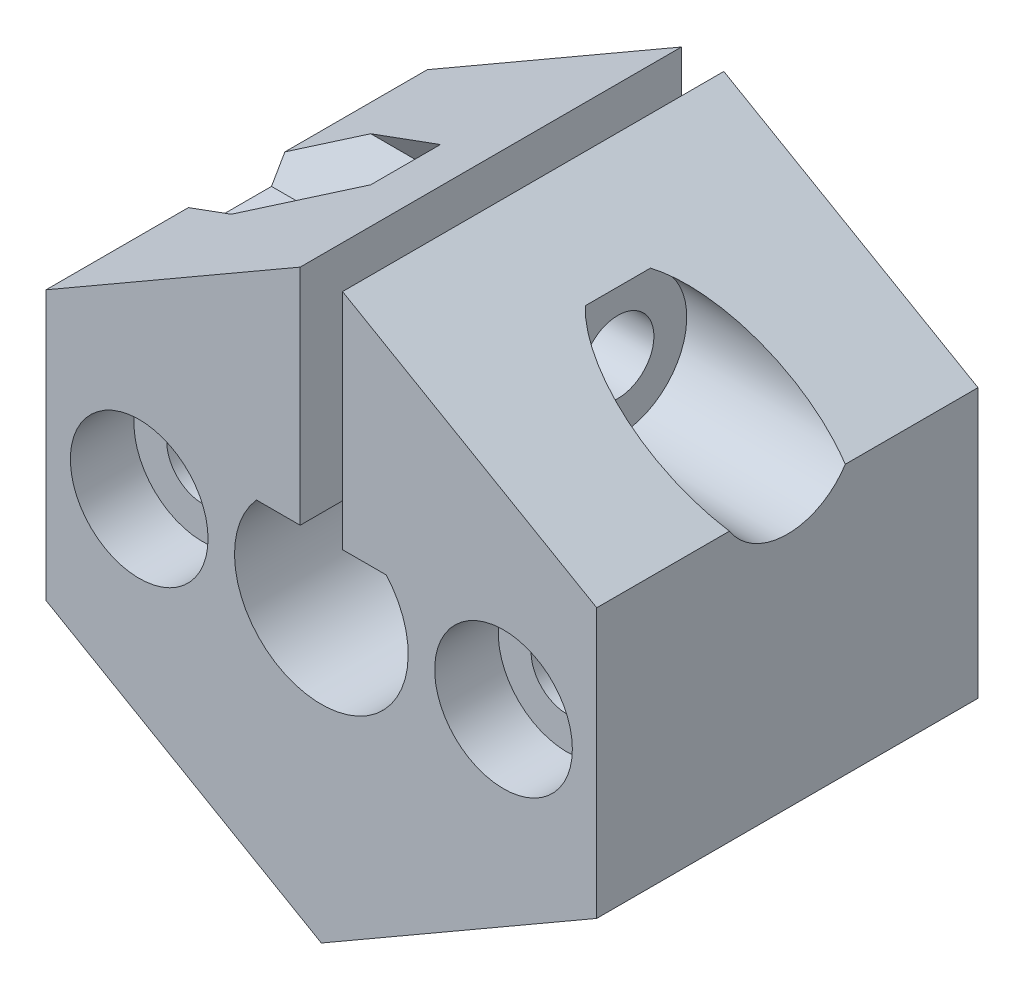
from build123d import *

# Parameters (mm, degrees)
BOSS_EXTRUDE1_DEPTH            = 18
SKETCH41_R                     = 1.7
CUT_EXTRUDE7_DEPTH             = 18
CBORE_FOR_M3_SHCS1_D           = 3.4
CBORE_FOR_M3_SHCS1_CBORE_D     = 6.5
CBORE_FOR_M3_SHCS1_CBORE_DEPTH = 3
CBORE_FOR_M3_SHCS2_D           = 3.4
CBORE_FOR_M3_SHCS2_CBORE_D     = 6.5
CBORE_FOR_M3_SHCS2_CBORE_DEPTH = 3
SKETCH52_R                     = 1.7
CUT_EXTRUDE10_DEPTH            = 15
CUT_EXTRUDE10_DEPTH_BACK       = 15
SKETCH58_R                     = 3.25
CUT_EXTRUDE11_DEPTH            = 8
CUT_EXTRUDE12_DEPTH            = 4
CUT_EXTRUDE12_DEPTH_BACK       = 6


with BuildPart() as part:
    # Sketch1 → Boss-Extrude1 (new body)
    with BuildSketch(Plane(origin=(0, 0, 0), x_dir=(0, 1, 0), z_dir=(0, 0, 1))):
        with BuildLine():
            Line((-6.350852961, -13), (6.350852961, -13))
            Line((6.350852961, -13), (13.279056191, -1))
            Line((13.279056191, -1), (2.724986242, -1))
            Line((2.724986242, -1), (2.724986242, -3.063404965))
            ThreePointArc((2.724986242, -3.063404965), (-1.678921738, -3.740484166), (-4.1, 0))
            ThreePointArc((-4.1, 0), (-1.678921738, 3.740484166), (2.724986242, 3.063404965))
            Line((2.724986242, 3.063404965), (2.724986242, 1))
            Line((2.724986242, 1), (13.279056191, 1))
            Line((13.279056191, 1), (6.350852961, 13))
            Line((6.350852961, 13), (-6.350852961, 13))
            Line((-6.350852961, 13), (-13.856406461, 0))
            Line((-13.856406461, 0), (-6.350852961, -13))
        make_face()
    extrude(amount=BOSS_EXTRUDE1_DEPTH)

    # Sketch41 → Cut-Extrude7 (cut)
    with BuildSketch(Plane(origin=(0, 0, 0), x_dir=(0, 1, 0), z_dir=(0, 0, 1))):
        with Locations((0, 8.6)):
            Circle(SKETCH41_R)
        with Locations((0, -8.6)):
            Circle(SKETCH41_R)
    extrude(amount=CUT_EXTRUDE7_DEPTH, mode=Mode.SUBTRACT)

    # CBORE for M3 SHCS1 (through all)
    with Locations(Plane(origin=(-8.6, 0, 18), x_dir=(1, 0, 0), z_dir=(0, 0, 1))):
        with Locations((0, 0)):
            CounterBoreHole(CBORE_FOR_M3_SHCS1_D / 2, CBORE_FOR_M3_SHCS1_CBORE_D / 2, CBORE_FOR_M3_SHCS1_CBORE_DEPTH)

    # CBORE for M3 SHCS2 (through all)
    with Locations(Plane(origin=(8.6, 0, 18), x_dir=(1, 0, 0), z_dir=(0, 0, 1))):
        with Locations((0, 0)):
            CounterBoreHole(CBORE_FOR_M3_SHCS2_D / 2, CBORE_FOR_M3_SHCS2_CBORE_D / 2, CBORE_FOR_M3_SHCS2_CBORE_DEPTH)

    # Sketch52 → Cut-Extrude10 (cut, two sides)
    with BuildSketch(Plane.YZ.offset(-1)) as cut_extrude10_sk:
        with Locations((8.106406461, 9)):
            Circle(SKETCH52_R)
    extrude(amount=CUT_EXTRUDE10_DEPTH, mode=Mode.SUBTRACT)
    extrude(cut_extrude10_sk.sketch, amount=-CUT_EXTRUDE10_DEPTH_BACK, mode=Mode.SUBTRACT)

    # Sketch58 → Cut-Extrude11 (cut)
    with BuildSketch(Plane.YZ.offset(13)):
        with Locations((8.106406461, 9)):
            Circle(SKETCH58_R)
    extrude(amount=-CUT_EXTRUDE11_DEPTH, mode=Mode.SUBTRACT)

    # Sketch60 → Cut-Extrude12 (cut, two sides)
    with BuildSketch(Plane.YZ.offset(-8)) as cut_extrude12_sk:
        Polygon((8.106406461, 5.709103466), (10.956406461, 7.354551733), (10.956406461, 10.645448267), (8.106406461, 12.290896534), (5.256406461, 10.645448267), (5.256406461, 7.354551733), align=None)
    extrude(amount=CUT_EXTRUDE12_DEPTH, mode=Mode.SUBTRACT)
    extrude(cut_extrude12_sk.sketch, amount=-CUT_EXTRUDE12_DEPTH_BACK, mode=Mode.SUBTRACT)


solid = part.part
